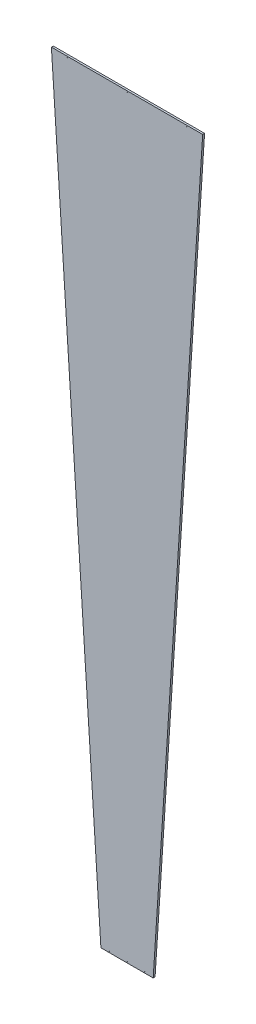
from build123d import *

# Parameters (mm, degrees)
EXTRUDE1_DEPTH = 0.16
SKETCH2_R      = 0.05
EXTRUDE2_DEPTH = 1.32


with BuildPart() as part:
    # Sketch1 → Extrude1 (new body, symmetric)
    with BuildSketch(Plane(origin=(0, 0, 0), x_dir=(-1, 0, 0), z_dir=(0, 0, -1))):
        Polygon((-4.387, 43.998003308), (4.387, 43.998003308), (12.697, 170.784102838), (-12.697, 170.784102838), align=None)
    extrude(amount=EXTRUDE1_DEPTH, both=True)

    # Sketch2 → Extrude2 (cut, through all)
    with BuildSketch(Plane.XY.offset(0.16)):
        with Locations((-3, 44.198003308)):
            Circle(SKETCH2_R)
        with Locations((0, 44.198003308)):
            Circle(SKETCH2_R)
        with Locations(Location((3, 44.198003308, 0), (0, 0, 180))):  # turned: the seam where the file's is
            Circle(SKETCH2_R)
        with Locations((0, 170.583003308)):
            Circle(SKETCH2_R)
        with Locations((-10, 170.583003308)):
            Circle(SKETCH2_R)
        with Locations(Location((10, 170.583003308, 0), (0, 0, 180))):  # turned: the seam where the file's is
            Circle(SKETCH2_R)
    extrude(amount=-EXTRUDE2_DEPTH, mode=Mode.SUBTRACT)


solid = part.part
